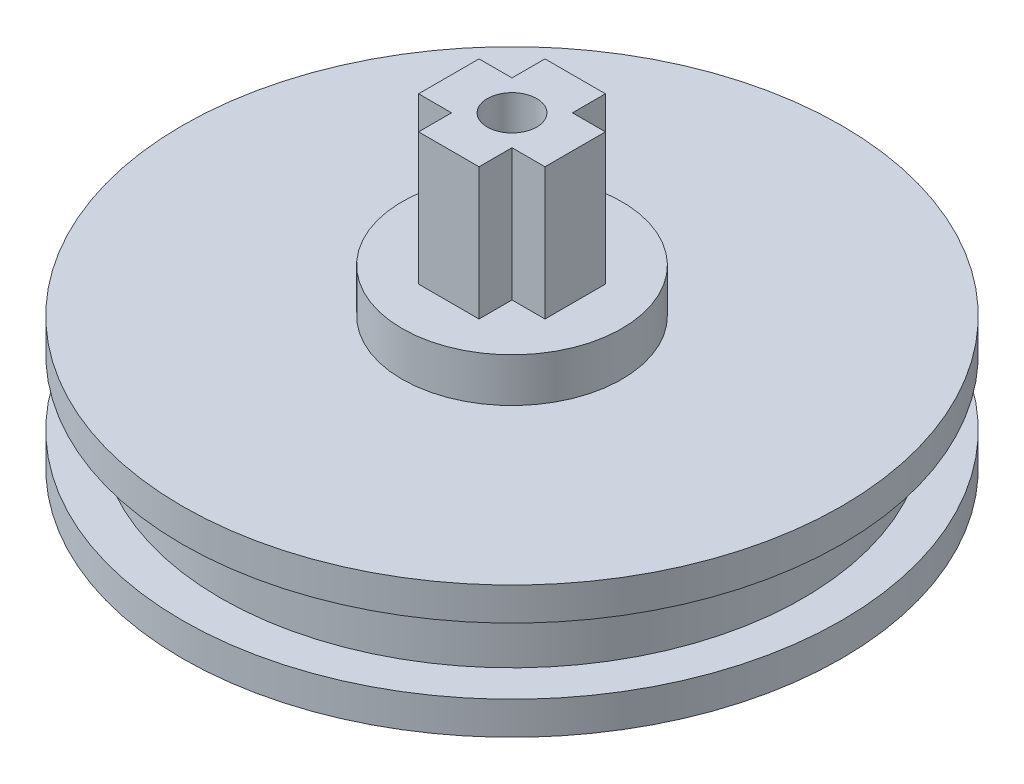
from build123d import *

# Parameters (mm, degrees)
SKETCH1_R           = 30
EXTRUDE_C_DEPTH     = 3
SKETCH2_R           = 26.5
BOSS_EXTRUDE2_DEPTH = 6
SKETCH3_R           = 30
BOSS_EXTRUDE3_DEPTH = 3
SKETCH4_W           = 5.5
SKETCH4_H           = 3
SKETCH4_W_2         = 3
SKETCH4_H_2         = 5.5
BOSS_EXTRUDE4_DEPTH = 16
SKETCH5_R           = 10
BOSS_EXTRUDE5_DEPTH = 4
SKETCH7_R           = 2.25
CUT_EXTRUDE1_DEPTH  = 46
SKETCH8_R           = 6.5
CUT_EXTRUDE2_DEPTH  = 3.5


with BuildPart() as part:
    # Sketch1 → Extrude c (new body)
    with BuildSketch(Plane(origin=(0, 0, 0), x_dir=(1, 0, 0), z_dir=(0, 1, 0))):
        Circle(SKETCH1_R)
    extrude(amount=EXTRUDE_C_DEPTH)

    # Sketch2 → Boss-Extrude2 (add)
    with BuildSketch(Plane(origin=(0, 3, 0), x_dir=(1, 0, 0), z_dir=(0, 1, 0))):
        Circle(SKETCH2_R)
    extrude(amount=BOSS_EXTRUDE2_DEPTH)

    # Sketch3 → Boss-Extrude3 (add)
    with BuildSketch(Plane(origin=(0, 9, 0), x_dir=(1, 0, 0), z_dir=(0, 1, 0))):
        Circle(SKETCH3_R)
    extrude(amount=BOSS_EXTRUDE3_DEPTH)

    # Sketch4 → Boss-Extrude4 (add)
    with BuildSketch(Plane(origin=(0, 12, 0), x_dir=(1, 0, 0), z_dir=(0, 1, 0))):
        with Locations((0, 4.25)):
            Rectangle(SKETCH4_W, SKETCH4_H)
        with Locations((-4.25, 0)):
            Rectangle(SKETCH4_W_2, SKETCH4_H_2)
        Rectangle(SKETCH4_W, SKETCH4_H_2)
        with Locations((0, -4.25)):
            Rectangle(SKETCH4_W, SKETCH4_H)
        with Locations((4.25, 0)):
            Rectangle(SKETCH4_W_2, SKETCH4_H_2)
    extrude(amount=BOSS_EXTRUDE4_DEPTH)

    # Sketch5 → Boss-Extrude5 (add)
    with BuildSketch(Plane(origin=(0, 12, 0), x_dir=(1, 0, 0), z_dir=(0, 1, 0))):
        Circle(SKETCH5_R)
    extrude(amount=BOSS_EXTRUDE5_DEPTH)

    # Sketch7 → Cut-Extrude1 (cut)
    with BuildSketch(Plane(origin=(0, 28, 0), x_dir=(1, 0, 0), z_dir=(0, 1, 0))):
        Circle(SKETCH7_R)
    extrude(amount=-CUT_EXTRUDE1_DEPTH, mode=Mode.SUBTRACT)

    # Sketch8 → Cut-Extrude2 (cut)
    with BuildSketch(Plane.XZ):
        Circle(SKETCH8_R)
    extrude(amount=-CUT_EXTRUDE2_DEPTH, mode=Mode.SUBTRACT)


solid = part.part
